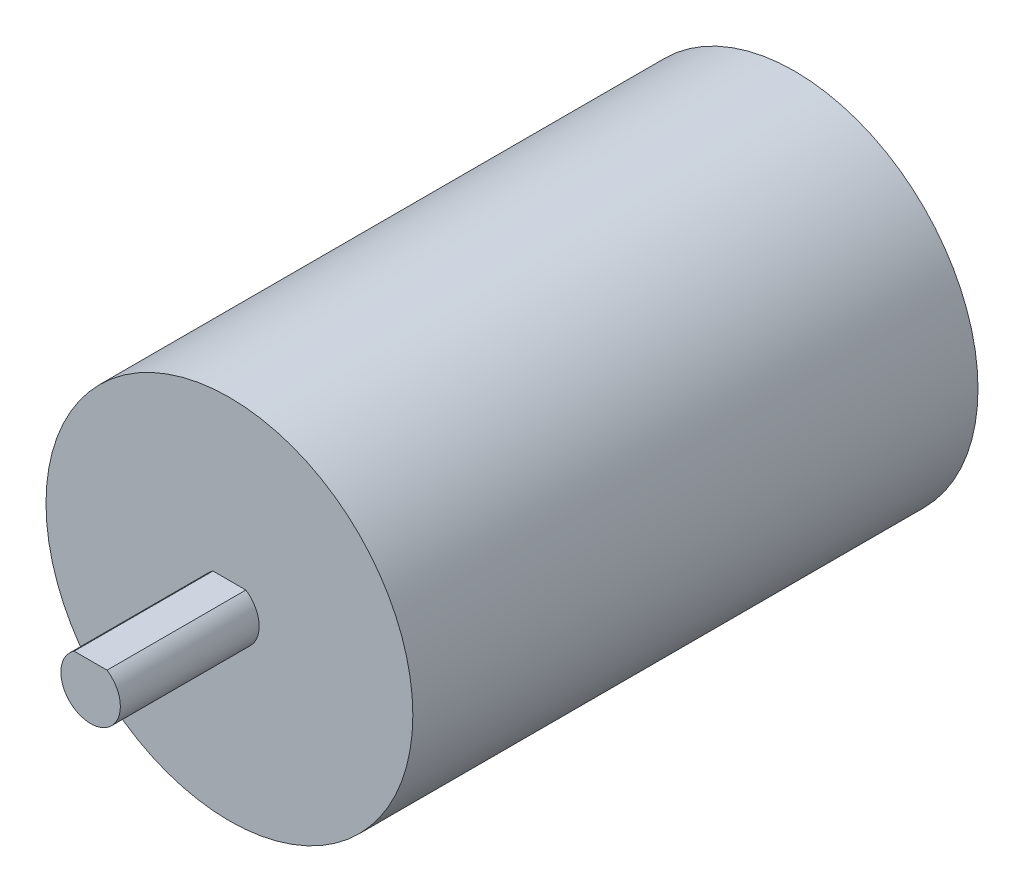
from build123d import *

# Parameters (mm, degrees)
SKETCH1_R           = 18.5
BOSS_EXTRUDE1_DEPTH = 57
BOSS_EXTRUDE2_DEPTH = 14


with BuildPart() as part:
    # Sketch1 → Boss-Extrude1 (new body)
    with BuildSketch(Plane.XY):
        Circle(SKETCH1_R)
    extrude(amount=BOSS_EXTRUDE1_DEPTH)

    # Sketch2 → Boss-Extrude2 (add)
    with BuildSketch(Plane.XY.offset(57)):
        with BuildLine():
            Line((1.658312395, 2.5), (-1.658312395, 2.5))
            ThreePointArc((-1.658312395, 2.5), (-1.418637165, -2.643382037), (3, 0))
            ThreePointArc((3, 0), (2.643382037, 1.418637165), (1.658312395, 2.5))
        make_face()
    extrude(amount=BOSS_EXTRUDE2_DEPTH)


solid = part.part
